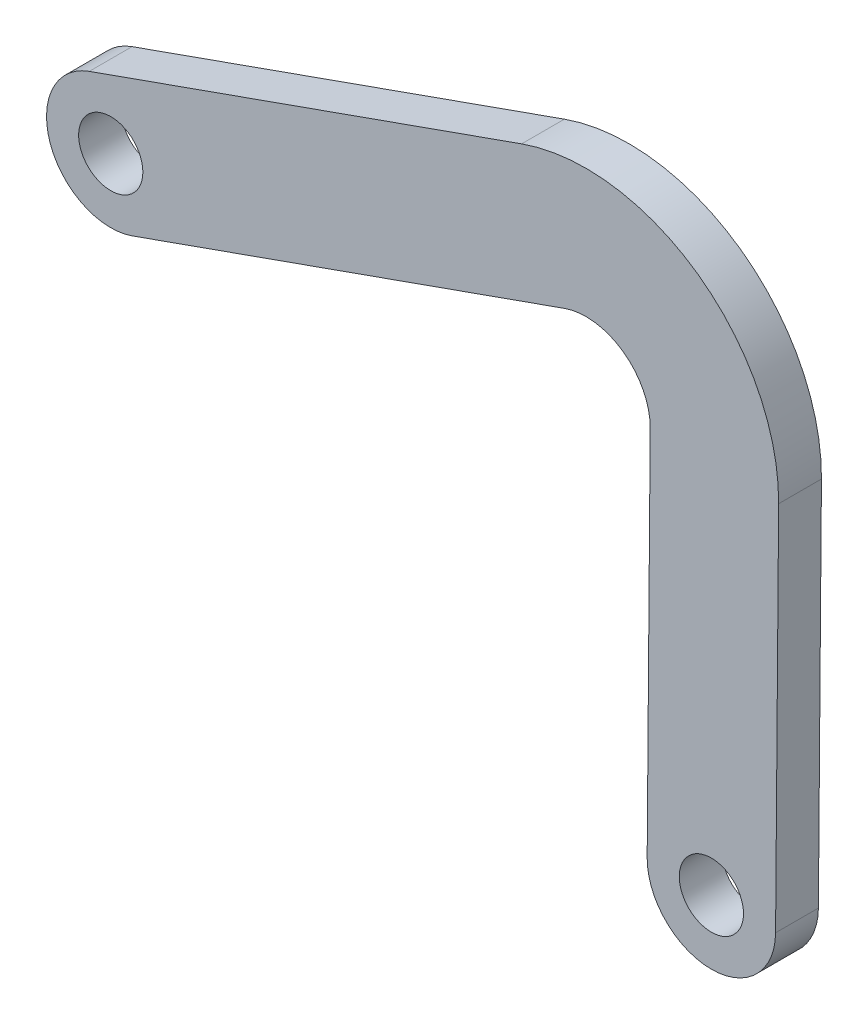
from build123d import *

# Parameters (mm, degrees)
ESTRUSIONE_ESTRUSIONE1_DEPTH = 2
SCHIZZO2_R                   = 1.5
TAGLIO_ESTRUSIONE1_DEPTH     = 2


with BuildPart() as part:
    # Schizzo1 → Estrusione-Estrusione1 (new body)
    with BuildSketch(Plane.XY):
        with BuildLine():
            Line((-21.580897542, 12.42042156), (-1.38290736, 19.585179227))
            ThreePointArc((-1.38290736, 19.585179227), (6.84830427, 18.432889155), (10.625632535, 11.029348887))
            Line((10.625632535, 11.029348887), (10.482922522, -6.402050228))
            ThreePointArc((10.482922522, -6.402050228), (7.458463026, -9.377389663), (4.48312359, -6.352930167))
            Line((4.48312359, -6.352930167), (4.625833603, 11.078468948))
            ThreePointArc((4.625833603, 11.078468948), (3.366724182, 13.546315704), (0.622986972, 13.930412395))
            Line((0.622986972, 13.930412395), (-19.57500321, 6.765654727))
            ThreePointArc((-19.57500321, 6.765654727), (-23.405333792, 8.590090978), (-21.580897542, 12.42042156))
        make_face()
    extrude(amount=ESTRUSIONE_ESTRUSIONE1_DEPTH)

    # Schizzo2 → Taglio-Estrusione1 (cut)
    with BuildSketch(Plane.XY.offset(2)):
        with Locations((7.483023056, -6.377490197)):
            Circle(SCHIZZO2_R)
        with Locations((-20.577950376, 9.593038144)):
            Circle(SCHIZZO2_R)
    extrude(amount=-TAGLIO_ESTRUSIONE1_DEPTH, mode=Mode.SUBTRACT)


solid = part.part
